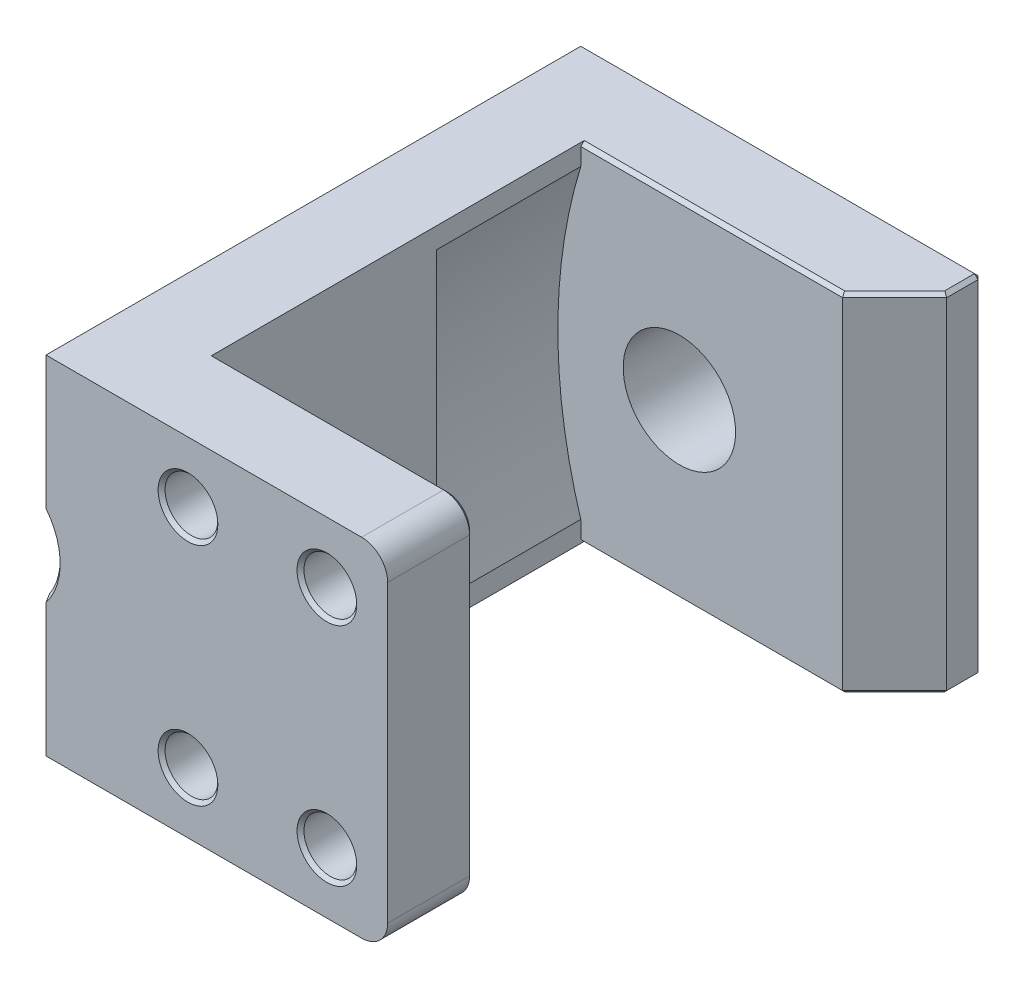
from build123d import *

# Parameters (mm, degrees)
SKETCH_1_R          = 3.2375
EXTRUDE_1_DEPTH     = 5
SKETCH_2_R          = 1.015
CUT_EXTRUDE_1_DEPTH = 2.85
CHAMFER_1_SIZE      = 0.2
EXTRUDE_2_DEPTH     = 1.55
CHAMFER_2_SIZE      = 0.2
FILLET_1_R          = 0.15
SKETCH_6_W          = 4.8
SKETCH_6_H          = 20
EXTRUDE_3_DEPTH     = 31
EXTRUDE_START       = 31
SKETCH_7_W          = 19.9
SKETCH_7_H          = 20
EXTRUDE_4_DEPTH     = 4.92
CUT_EXTRUDE_START   = 26.08
SKETCH_8_R          = 1.52
CUT_EXTRUDE_2_DEPTH = 4.92
CHAMFER_3_SIZE      = 0.2
CUT_EXTRUDE_START_2 = 31
CUT_EXTRUDE_3_DEPTH = 31
FILLET_2_R          = 1.5
CUT_EXTRUDE_4_DEPTH = 1.5
CHAMFER_4_SIZE      = 0.2
SKETCH_13_W         = 3.2
SKETCH_13_H         = 20
EXTRUDE_5_DEPTH     = 5
CHAMFER_5_SIZE      = 3
CUT_EXTRUDE_START_3 = 5
CUT_EXTRUDE_5_DEPTH = 7
CHAMFER_7_SIZE      = 1.3
CHAMFER_8_SIZE      = 0.2


with BuildPart() as part:
    # 草图1 → 凸台-拉伸1 (new body)
    with BuildSketch(Plane.XY):
        Polygon((13.5775, 0), (13.5775, 10), (-10.48, 10), (-10.48, 0), (-10.48, -10), (13.5775, -10), align=None)
        Circle(SKETCH_1_R, mode=Mode.SUBTRACT)
    extrude(amount=EXTRUDE_1_DEPTH)

    # 草图2 → 切除-拉伸1 (cut)
    with BuildSketch(Plane.XY):
        with Locations((0, 5.6)):
            Circle(SKETCH_2_R)
        with Locations((0, -5.6)):
            Circle(SKETCH_2_R)
    extrude(amount=CUT_EXTRUDE_1_DEPTH, mode=Mode.SUBTRACT)

    # 倒角1
    chamfer_1_edges = [part.edges().sort_by_distance(p)[0] for p in [
        (-1.015, 5.6, 0),
        (-1.015, -5.6, 0),
    ]]
    chamfer(chamfer_1_edges, length=CHAMFER_1_SIZE)

    # 草图5 → 凸台-拉伸2 (add)
    with BuildSketch(Plane.XY):
        Polygon((-9, 7.275), (-10.48, 7.275), (-10.48, -7.275), (-9, -7.275), (-9, 0), align=None)
    extrude(amount=-EXTRUDE_2_DEPTH)

    # 倒角2
    chamfer_2_edges = [part.edges().sort_by_distance(p)[0] for p in [
        (-9.74, -7.275, -1.55),
        (-10.48, 0, -1.55),
        (-9.74, 7.275, -1.55),
        (-9, 0, -1.55),
    ]]
    chamfer(chamfer_2_edges, length=CHAMFER_2_SIZE)

    # 圆角1
    fillet_1_edges = [part.edges().sort_by_distance(p)[0] for p in [
        (-10.48, -7.275, -0.675),
        (-9, -7.275, -0.675),
        (-9, 7.275, -0.675),
        (-10.48, 7.275, -0.675),
    ]]
    fillet(fillet_1_edges, radius=FILLET_1_R)

    # 草图6 → 凸台-拉伸3 (add)
    with BuildSketch(Plane.XY):
        with Locations((-8.08, 0)):
            Rectangle(SKETCH_6_W, SKETCH_6_H)
    extrude(amount=EXTRUDE_3_DEPTH)

    # 草图7 → 凸台-拉伸4 (add)
    with BuildSketch(Plane.XY.offset(EXTRUDE_START)):
        with Locations((3.6275, 0)):
            Rectangle(SKETCH_7_W, SKETCH_7_H)
    extrude(amount=-EXTRUDE_4_DEPTH)

    # 草图8 → 切除-拉伸2 (cut)
    with BuildSketch(Plane.XY.offset(CUT_EXTRUDE_START)):
        with Locations((-2.3025, 6.5)):
            Circle(SKETCH_8_R)
        with Locations((5.6975, 6.5)):
            Circle(SKETCH_8_R)
        with Locations((5.6975, -6.5)):
            Circle(SKETCH_8_R)
        with Locations((-2.3025, -6.5)):
            Circle(SKETCH_8_R)
    extrude(amount=CUT_EXTRUDE_2_DEPTH, mode=Mode.SUBTRACT)

    # 倒角3
    chamfer_3_edges = [part.edges().sort_by_distance(p)[0] for p in [
        (-3.8225, -6.5, 31),
        (4.1775, -6.5, 31),
        (4.1775, 6.5, 31),
        (-3.8225, 6.5, 31),
    ]]
    chamfer(chamfer_3_edges, length=CHAMFER_3_SIZE)

    # 草图10 → 切除-拉伸3 (cut)
    with BuildSketch(Plane.XY.offset(CUT_EXTRUDE_START_2)):
        Polygon((9.198987738, 6.5), (9.198987738, -10), (13.5775, -10), (13.5775, 10), (9.198987738, 10), align=None)
    extrude(amount=-CUT_EXTRUDE_3_DEPTH, mode=Mode.SUBTRACT)

    # 圆角2
    fillet_2_edges = [part.edges().sort_by_distance(p)[0] for p in [
        (9.198987738, 10, 28.54),
        (9.198987738, -10, 28.54),
    ]]
    fillet(fillet_2_edges, radius=FILLET_2_R)

    # 草图11 → 切除-拉伸4 (cut)
    with BuildSketch(Plane.XY.offset(CUT_EXTRUDE_START_2)):
        with BuildLine():
            Line((-10.48, 2.007504789), (-10.48, -2.007504789))
            ThreePointArc((-10.48, -2.007504789), (-9.862877127, 0), (-10.48, 2.007504789))
        make_face()
    extrude(amount=-CUT_EXTRUDE_4_DEPTH, mode=Mode.SUBTRACT)

    # 倒角4
    chamfer_4_edges = [part.edges().sort_by_distance(p)[0] for p in [
        (1.009493869, 10, 26.08),
        (1.009493869, -10, 26.08),
        (9.198987738, 0, 26.08),
        (8.759647909, 9.560660172, 26.08),
        (8.759647909, -9.560660172, 26.08),
        (-10.48, 0, 29.5),
        (-9.862877127, 0, 31),
    ]]
    chamfer(chamfer_4_edges, length=CHAMFER_4_SIZE)

    # 草图13 → 凸台-拉伸5 (add)
    with BuildSketch(Plane.XY):
        with Locations((10.798987738, 0)):
            Rectangle(SKETCH_13_W, SKETCH_13_H)
    extrude(amount=EXTRUDE_5_DEPTH)

    # 倒角5
    chamfer_5_edges = [part.edges().sort_by_distance(p)[0] for p in [
        (12.398987738, 0, 5),
    ]]
    chamfer(chamfer_5_edges, length=CHAMFER_5_SIZE)

    # 草图14 → 切除-拉伸5 (cut)
    with BuildSketch(Plane.XY.offset(CUT_EXTRUDE_START_3)):
        with BuildLine():
            Line((-5.284271247, 10), (-5.284271247, -10))
            ThreePointArc((-5.284271247, -10), (-7, 0), (-5.284271247, 10))
        make_face()
    extrude(amount=CUT_EXTRUDE_5_DEPTH, mode=Mode.SUBTRACT)

    # 倒角7
    chamfer_7_edges = [part.edges().sort_by_distance(p)[0] for p in [
        (-5.68, 0, 12),
    ]]
    chamfer(chamfer_7_edges, length=CHAMFER_7_SIZE)

    # 倒角8
    chamfer_8_edges = [part.edges().sort_by_distance(p)[0] for p in [
        (1.859493869, -10, 5),
        (0.959493869, 10, 0),
        (12.398987738, 0, 0),
        (12.398987738, 10, 1),
        (12.398987738, -10, 1),
        (10.898987738, -10, 3.5),
        (1.859493869, 10, 5),
        (10.898987738, 10, 3.5),
        (0.959493869, -10, 0),
    ]]
    chamfer(chamfer_8_edges, length=CHAMFER_8_SIZE)


solid = part.part
